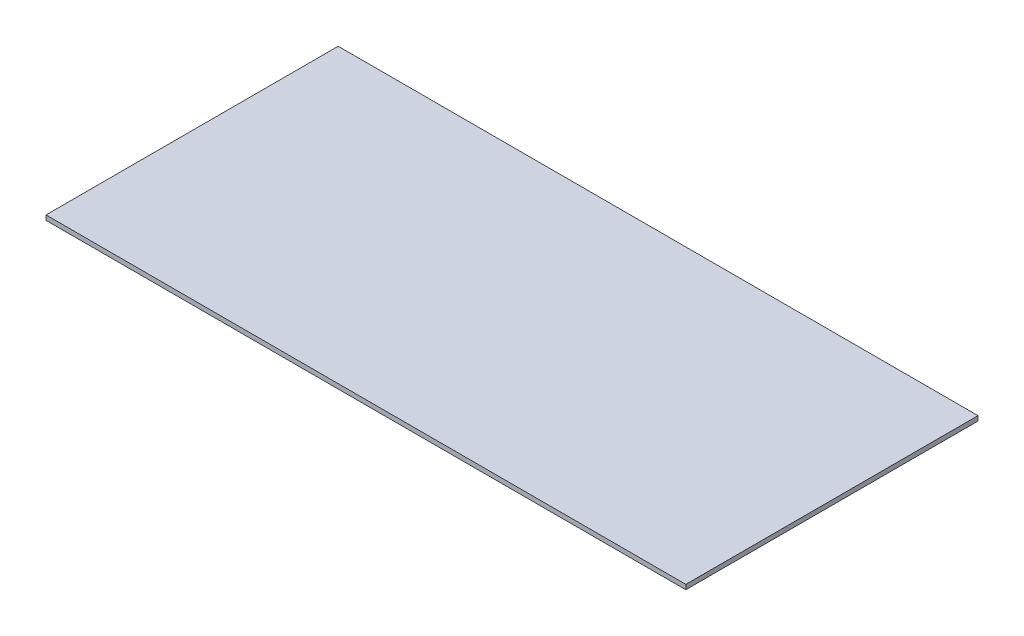
from build123d import *

# Parameters (mm, degrees)
SKETCH1_W           = 1730
SKETCH1_H           = 790
BOSS_EXTRUDE1_DEPTH = 12.7


with BuildPart() as part:
    # Sketch1 → Boss-Extrude1 (new body)
    with BuildSketch(Plane(origin=(0, 0, 0), x_dir=(1, 0, 0), z_dir=(0, 1, 0))):
        Rectangle(SKETCH1_W, SKETCH1_H)
    extrude(amount=BOSS_EXTRUDE1_DEPTH)


solid = part.part
